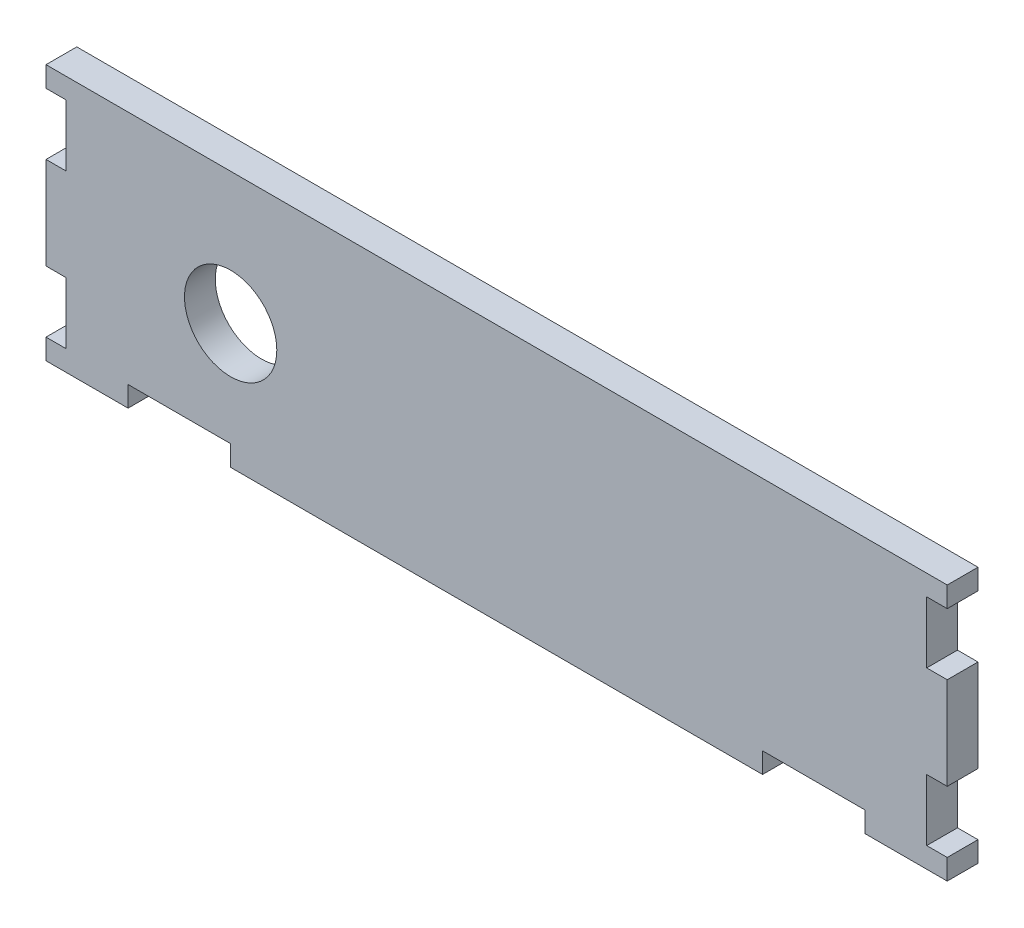
from build123d import *

# Parameters (mm, degrees)
ESBO_O1_R                = 4.5
RESSALTO_EXTRUS_O1_DEPTH = 3
ESBO_O1_9_R              = 4
ESBO_O1_9_R_2            = 2
RESSALTO_EXTRUS_O2_DEPTH = 5.5


with BuildPart() as part:
    # Esboço1 → Ressalto-extrusão1 (new body)
    with BuildSketch(Plane.XY):
        Polygon((7.074470574, -10.667826967), (58.928805727, -10.667826967), (58.928805727, -8.667826967), (68.928805727, -8.667826967), (68.928805727, -10.667826967), (76.928805727, -10.667826967), (76.928805727, -8.667826967), (74.928805727, -8.667826967), (74.928805727, -2.667826967), (76.928805727, -2.667826967), (76.928805727, 6.332173033), (74.928805727, 6.332173033), (74.928805727, 12.332173033), (76.928805727, 12.332173033), (76.928805727, 14.332173033), (-10.925529426, 14.332173033), (-10.925529426, 12.332173033), (-8.987091583, 12.332173033), (-8.987091583, 6.332173033), (-10.925529426, 6.332173033), (-10.925529426, -2.667826967), (-8.987091583, -2.667826967), (-8.987091583, -8.667826967), (-10.925529426, -8.667826967), (-10.925529426, -10.667826967), (-2.925529426, -10.667826967), (-2.925529426, -8.667826967), (7.074470574, -8.667826967), align=None)
        with Locations((7.074470574, 1.482173033)):
            Circle(ESBO_O1_R, mode=Mode.SUBTRACT)
    extrude(amount=-RESSALTO_EXTRUS_O1_DEPTH)

    # Esboço1<9> → Ressalto-extrusão2 (add)
    # profile 1 of 2: a face of its own
    with BuildSketch(Plane.XY):
        with Locations((24.354470574, 1.482173033)):
            Circle(ESBO_O1_9_R)
        with Locations((24.354470574, 1.482173033)):
            Circle(ESBO_O1_9_R_2, mode=Mode.SUBTRACT)
    # profile 2 of 2: a face of its own
    with BuildSketch(Plane.XY):
        with Locations((41.854470574, 1.482173033)):
            Circle(ESBO_O1_9_R)
        with Locations((41.854470574, 1.482173033)):
            Circle(ESBO_O1_9_R_2, mode=Mode.SUBTRACT)
    extrude(amount=-RESSALTO_EXTRUS_O2_DEPTH)


solid = part.part
